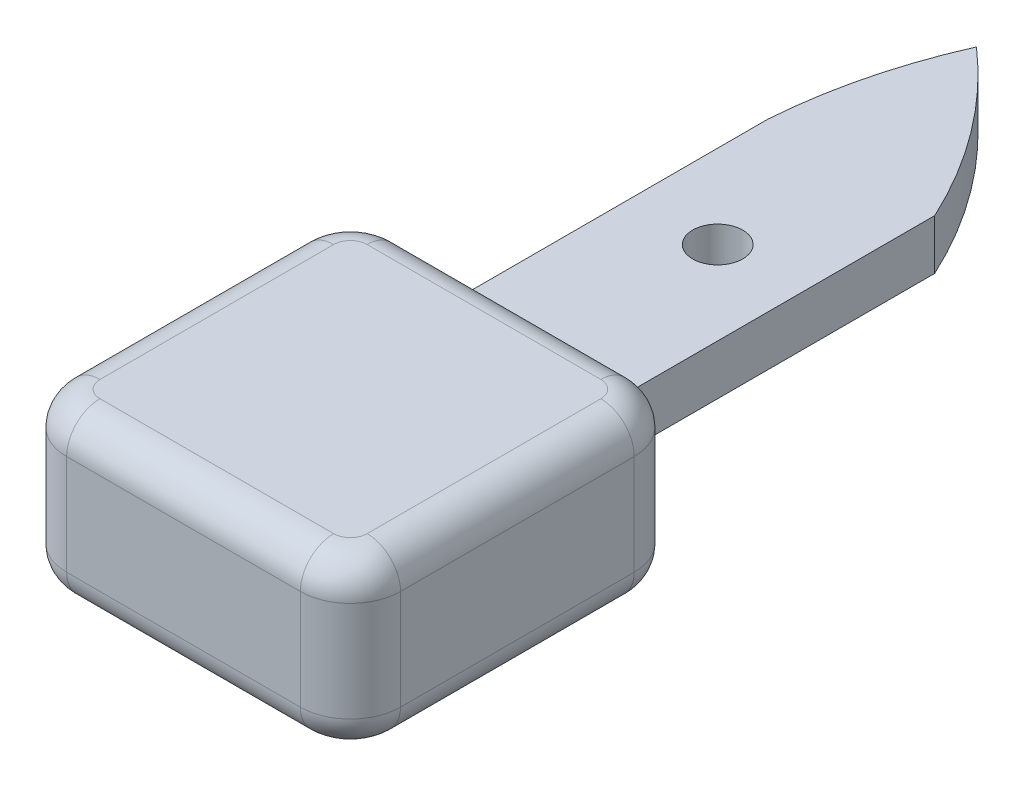
from build123d import *

# Parameters (mm, degrees)
SKETCH1_R           = 1.5
BOSS_EXTRUDE1_DEPTH = 3
BOSS_EXTRUDE2_DEPTH = 5
FILLET1_R           = 2


with BuildPart() as part:
    # Sketch1 → Boss-Extrude1 (new body)
    with BuildSketch(Plane(origin=(0, 0, 0), x_dir=(1, 0, 0), z_dir=(0, 1, 0))):
        with BuildLine():
            Line((0, 0), (0, 20))
            ThreePointArc((0, 20), (0.817293204, 25.108176699), (2.5, 30))
            ThreePointArc((2.5, 30), (6.776610811, 25.394958109), (10, 20))
            Line((10, 20), (10, 0))
            Line((10, 0), (12, 0))
            ThreePointArc((12, 0), (14.121320344, -0.878679656), (15, -3))
            Line((15, -3), (15, -17))
            ThreePointArc((15, -17), (14.121320344, -19.121320344), (12, -20))
            Line((12, -20), (-2, -20))
            ThreePointArc((-2, -20), (-4.121320344, -19.121320344), (-5, -17))
            Line((-5, -17), (-5, -3))
            ThreePointArc((-5, -3), (-4.121320344, -0.878679656), (-2, 0))
            Line((-2, 0), (0, 0))
        make_face()
        with Locations((5, 12)):
            Circle(SKETCH1_R, mode=Mode.SUBTRACT)
    extrude(amount=BOSS_EXTRUDE1_DEPTH)

    # Sketch2 → Boss-Extrude2 (add, symmetric)
    with BuildSketch(Plane(origin=(0, 1.5, 0), x_dir=(1, 0, 0), z_dir=(0, 1, 0))):
        with BuildLine():
            Line((0, 0), (-2, 0))
            ThreePointArc((-2, 0), (-4.121320344, -0.878679656), (-5, -3))
            Line((-5, -3), (-5, -17))
            ThreePointArc((-5, -17), (-4.121320344, -19.121320344), (-2, -20))
            Line((-2, -20), (12, -20))
            ThreePointArc((12, -20), (14.121320344, -19.121320344), (15, -17))
            Line((15, -17), (15, -3))
            ThreePointArc((15, -3), (14.121320344, -0.878679656), (12, 0))
            Line((12, 0), (10, 0))
            Line((10, 0), (0, 0))
        make_face()
    extrude(amount=BOSS_EXTRUDE2_DEPTH, both=True)

    # Fillet1
    fillet1_edges = [part.edges().sort_by_distance(p)[0] for p in [
        (-4.121320344, -3.5, 0.878679656),
        (-5, -3.5, 10),
        (-4.121320344, -3.5, 19.121320344),
        (5, -3.5, 20),
        (14.121320344, -3.5, 19.121320344),
        (15, -3.5, 10),
        (14.121320344, -3.5, 0.878679656),
        (5, -3.5, 0),
        (5, 6.5, 0),
        (-4.121320344, 6.5, 0.878679656),
        (-5, 6.5, 10),
        (-4.121320344, 6.5, 19.121320344),
        (5, 6.5, 20),
        (14.121320344, 6.5, 19.121320344),
        (15, 6.5, 10),
        (14.121320344, 6.5, 0.878679656),
    ]]
    fillet(fillet1_edges, radius=FILLET1_R)


solid = part.part
